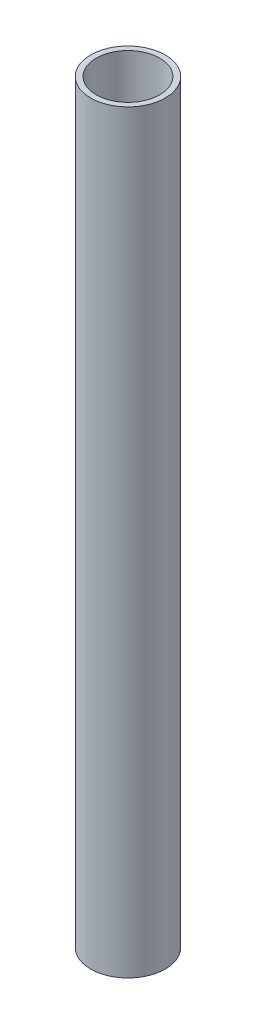
from build123d import *

# Parameters (mm, degrees)
SKETCH5_R   = 13.5
SKETCH5_R_2 = 11.5


with BuildPart() as part:
    # Sweep2: sweep along a path in Sketch4
    with BuildLine(Plane(origin=(0, 0, 0), x_dir=(0, 0, -1), z_dir=(1, 0, 0))) as sweep2_path:
        Line((0, 0), (0, 273))
    # Sketch5 → Sweep2 (sweep)
    with BuildSketch(Plane(origin=(0, 0, 0), x_dir=(1, 0, 0), z_dir=(0, 1, 0))):
        Circle(SKETCH5_R)
        Circle(SKETCH5_R_2, mode=Mode.SUBTRACT)
    sweep(path=sweep2_path.line)


solid = part.part
